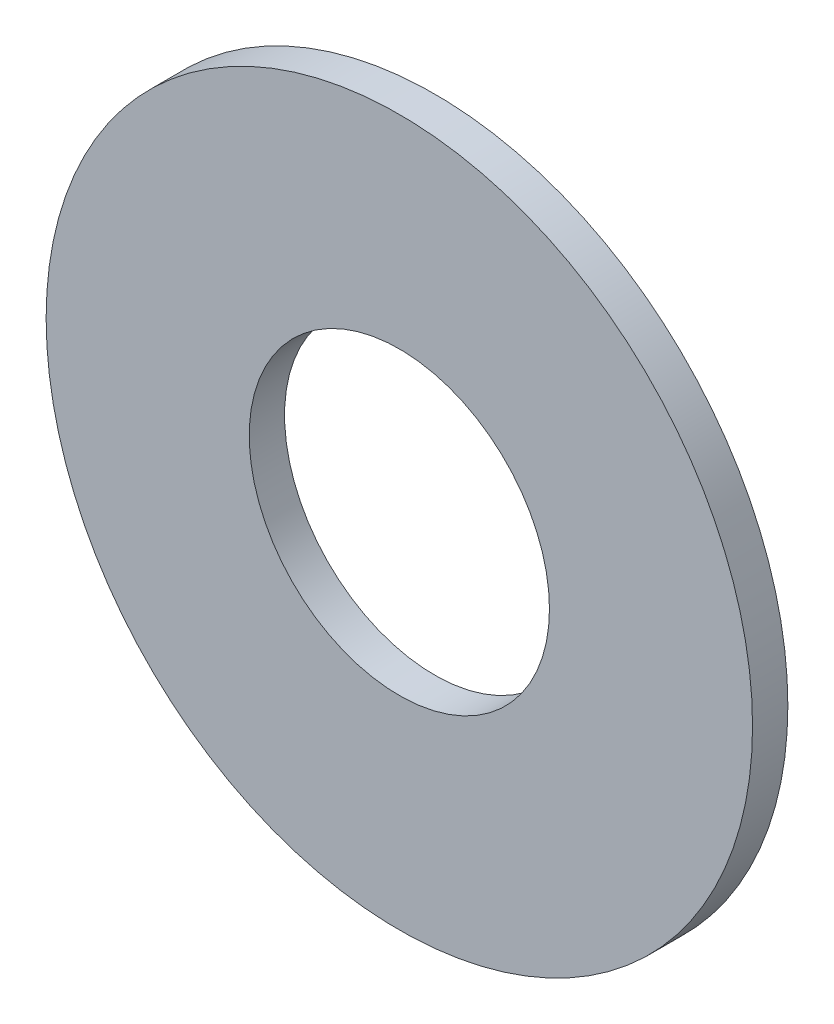
from build123d import *

# Parameters (mm, degrees)
SKETCH_1_R      = 10
SKETCH_1_R_2    = 4.25
EXTRUDE_1_DEPTH = 1


with BuildPart() as part:
    # Эскиз1 → Бобышка-Вытянуть1 (new body)
    with BuildSketch(Plane.XY):
        Circle(SKETCH_1_R)
        Circle(SKETCH_1_R_2, mode=Mode.SUBTRACT)
    extrude(amount=EXTRUDE_1_DEPTH)


solid = part.part
